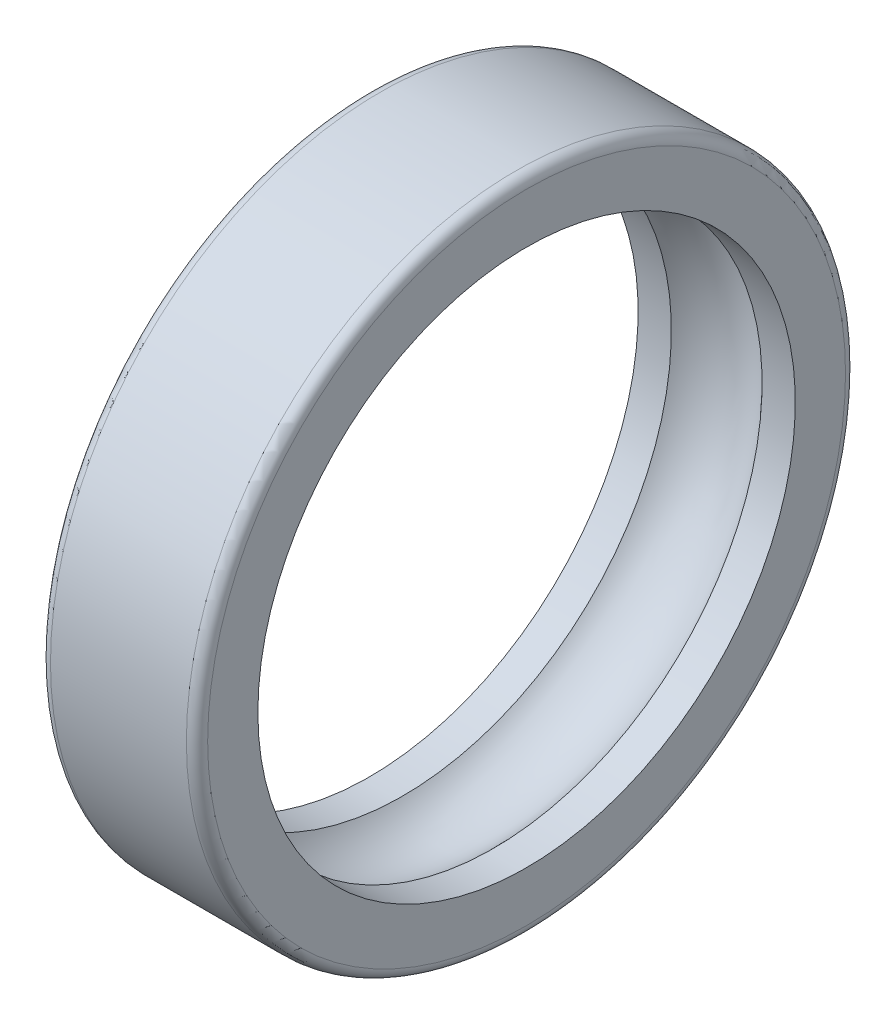
from build123d import *

# Parameters (mm, degrees)
FILLET1_R = 2.1


with BuildPart() as part:
    # Sketch1 → Revolve1 (revolve)
    with BuildSketch(Plane.XY):
        with BuildLine():
            Line((-15.5, 65), (15.5, 65))
            Line((15.5, 65), (15.5, 53))
            Line((15.5, 53), (8.94427191, 53))
            ThreePointArc((8.94427191, 53), (0, 57), (-8.94427191, 53))
            Line((-8.94427191, 53), (-15.5, 53))
            Line((-15.5, 53), (-15.5, 65))
        make_face()
    revolve(axis=Axis((0, 0, 0), (1, 0, 0)))

    # Fillet1
    fillet1_edges = [part.edges().sort_by_distance(p)[0] for p in [
        (-15.5, -65, 0),
        (15.5, -65, 0),
    ]]
    fillet(fillet1_edges, radius=FILLET1_R)


solid = part.part
